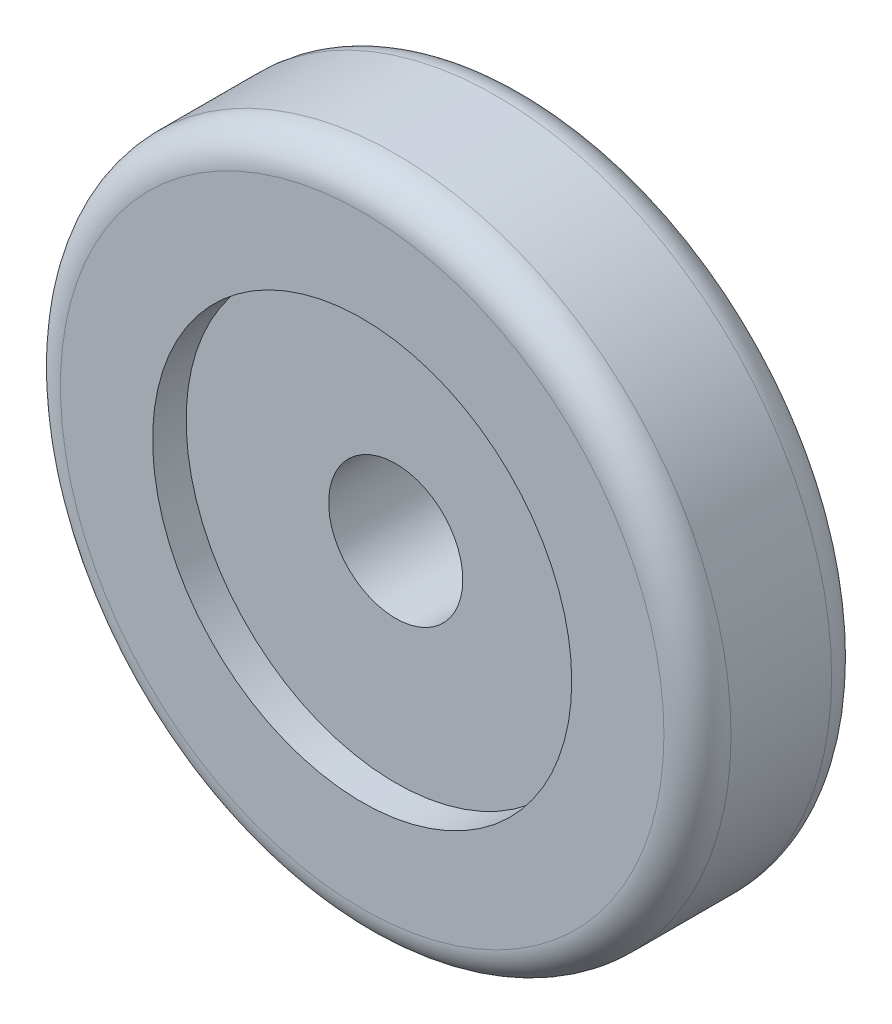
from build123d import *

# Parameters (mm, degrees)
SKETCH1_R           = 20
BOSS_EXTRUDE1_DEPTH = 10
SKETCH2_R           = 4
CUT_EXTRUDE1_DEPTH  = 11
SKETCH3_R           = 12.5
CUT_EXTRUDE2_DEPTH  = 2
FILLET1_R           = 2


with BuildPart() as part:
    # Sketch1 → Boss-Extrude1 (new body)
    with BuildSketch(Plane.XY):
        Circle(SKETCH1_R)
    extrude(amount=BOSS_EXTRUDE1_DEPTH)

    # Sketch2 → Cut-Extrude1 (cut, through all)
    with BuildSketch(Plane.XY):
        Circle(SKETCH2_R)
    extrude(amount=CUT_EXTRUDE1_DEPTH, mode=Mode.SUBTRACT)

    # Sketch3 → Cut-Extrude2 (cut)
    with BuildSketch(Plane.XY.offset(10)):
        Circle(SKETCH3_R)
    extrude(amount=-CUT_EXTRUDE2_DEPTH, mode=Mode.SUBTRACT)

    # Fillet1
    fillet1_edges = [part.edges().sort_by_distance(p)[0] for p in [
        (-20, 0, 0),
        (-20, 0, 10),
    ]]
    fillet(fillet1_edges, radius=FILLET1_R)


solid = part.part
